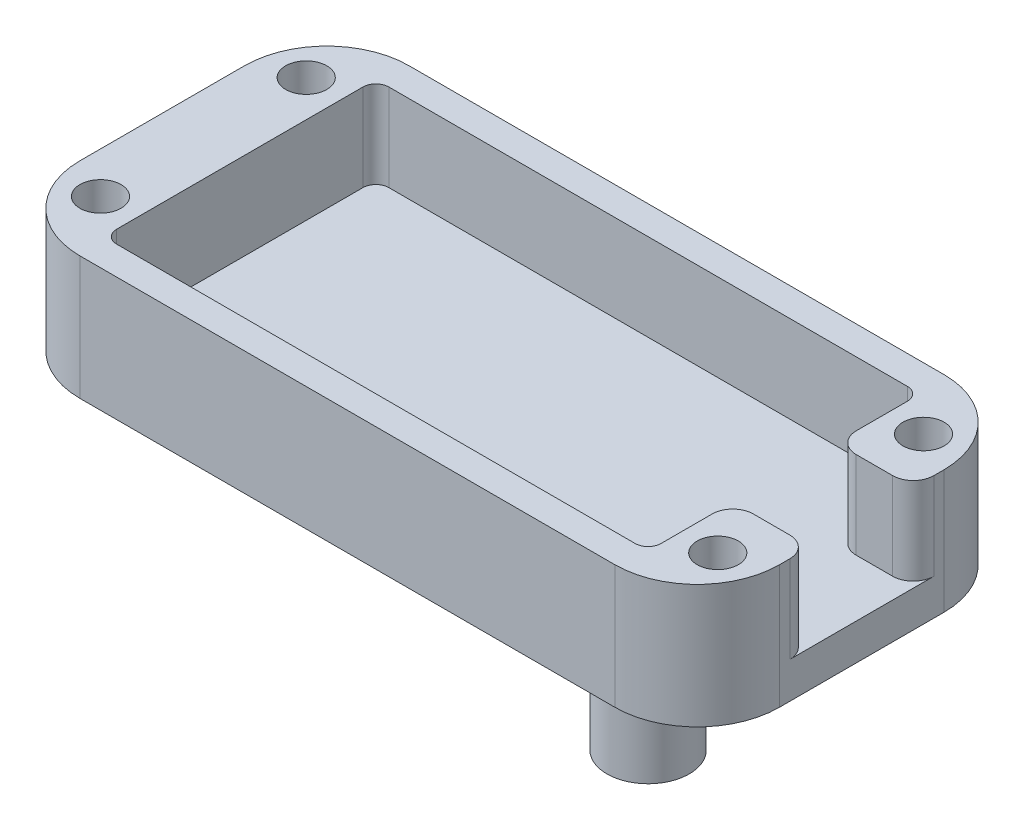
from build123d import *

# Parameters (mm, degrees)
SKETCH1_W           = 53.975
SKETCH1_H           = 25.4
BOSS_EXTRUDE1_DEPTH = 9.525
SKETCH2_W           = 42
SKETCH2_H           = 21
CUT_EXTRUDE1_DEPTH  = 6.725
FILLET1_R           = 1
SKETCH3_R           = 3.175
BOSS_EXTRUDE2_DEPTH = 14.2875
SKETCH4_R           = 1.5875
CUT_EXTRUDE2_DEPTH  = 9.525
FILLET2_R           = 6.35
SKETCH5_W           = 5.9875
SKETCH5_H           = 7.9375
CUT_EXTRUDE3_DEPTH  = 6.725
FILLET3_R           = 1.5875


with BuildPart() as part:
    # Sketch1 → Boss-Extrude1 (new body)
    with BuildSketch(Plane(origin=(0, 0, 0), x_dir=(1, 0, 0), z_dir=(0, 1, 0))):
        with Locations((26.9875, 12.7)):
            Rectangle(SKETCH1_W, SKETCH1_H)
    extrude(amount=BOSS_EXTRUDE1_DEPTH)

    # Sketch2 → Cut-Extrude1 (cut)
    with BuildSketch(Plane(origin=(0, 9.525, 0), x_dir=(1, 0, 0), z_dir=(0, 1, 0))):
        with Locations((26.9875, 12.7)):
            Rectangle(SKETCH2_W, SKETCH2_H)
    extrude(amount=-CUT_EXTRUDE1_DEPTH, mode=Mode.SUBTRACT)

    # Fillet1
    fillet1_edges = [part.edges().sort_by_distance(p)[0] for p in [
        (5.9875, 6.1625, -2.2),
        (5.9875, 6.1625, -23.2),
        (47.9875, 6.1625, -23.2),
        (47.9875, 6.1625, -2.2),
    ]]
    fillet(fillet1_edges, radius=FILLET1_R)

    # Sketch3 → Boss-Extrude2 (add)
    with BuildSketch(Plane.XZ):
        with Locations((37.4875, -12.7)):
            Circle(SKETCH3_R)
    extrude(amount=BOSS_EXTRUDE2_DEPTH)

    # Sketch4 → Cut-Extrude2 (cut)
    with BuildSketch(Plane(origin=(0, 9.525, 0), x_dir=(1, 0, 0), z_dir=(0, 1, 0))):
        with Locations((3.175, 20.6375)):
            Circle(SKETCH4_R)
        with Locations((3.175, 4.7625)):
            Circle(SKETCH4_R)
        with Locations((50.8, 20.6375)):
            Circle(SKETCH4_R)
        with Locations((50.8, 4.7625)):
            Circle(SKETCH4_R)
    extrude(amount=-CUT_EXTRUDE2_DEPTH, mode=Mode.SUBTRACT)

    # Fillet2
    fillet2_edges = [part.edges().sort_by_distance(p)[0] for p in [
        (0, 4.7625, -25.4),
        (53.975, 4.7625, -25.4),
        (53.975, 4.7625, 0),
        (0, 4.7625, 0),
    ]]
    fillet(fillet2_edges, radius=FILLET2_R)

    # Sketch5 → Cut-Extrude3 (cut)
    with BuildSketch(Plane(origin=(0, 9.525, 0), x_dir=(1, 0, 0), z_dir=(0, 1, 0))):
        with Locations((50.98125, 12.7)):
            Rectangle(SKETCH5_W, SKETCH5_H)
    extrude(amount=-CUT_EXTRUDE3_DEPTH, mode=Mode.SUBTRACT)

    # Fillet3
    fillet3_edges = [part.edges().sort_by_distance(p)[0] for p in [
        (53.975, 6.1625, -8.73125),
        (47.9875, 6.1625, -8.73125),
        (47.9875, 6.1625, -16.66875),
        (53.975, 6.1625, -16.66875),
    ]]
    fillet(fillet3_edges, radius=FILLET3_R)


solid = part.part
